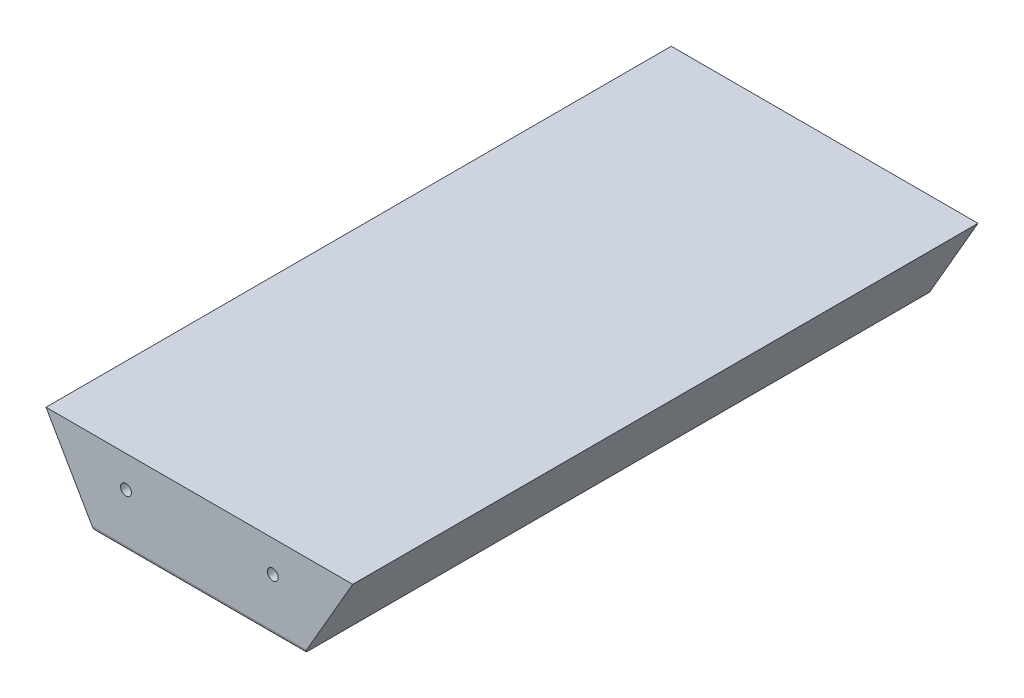
from build123d import *

# Parameters (mm, degrees)
BOSS_EXTRUDE1_DEPTH = 100
SKETCH3_R           = 5
CUT_EXTRUDE2_DEPTH  = 15
BOSS_EXTRUDE5_DEPTH = 50
BOSS_EXTRUDE6_DEPTH = 48
FILLET1_R           = 1.8
SKETCH11_R          = 2.6
CUT_EXTRUDE3_DEPTH  = 15
SKETCH12_R          = 2.6
CUT_EXTRUDE4_DEPTH  = 15


with BuildPart() as part:
    # Sketch1 → Boss-Extrude1 (new body, symmetric)
    with BuildSketch(Plane.XY):
        Polygon((50, 0), (-50, 0), (-73.094010768, 40), (73.094010768, 40), align=None)
    extrude(amount=BOSS_EXTRUDE1_DEPTH, both=True)

    # Sketch3 → Cut-Extrude2 (cut)
    with BuildSketch(Plane.XZ):
        with Locations((0, 70)):
            Circle(SKETCH3_R)
        with Locations((0, -70)):
            Circle(SKETCH3_R)
        Circle(SKETCH3_R)
    extrude(amount=-CUT_EXTRUDE2_DEPTH, mode=Mode.SUBTRACT)

    # Sketch9 → Boss-Extrude5 (add)
    with BuildSketch(Plane(origin=(0, 0, -100), x_dir=(-1, 0, 0), z_dir=(0, 0, -1))):
        Polygon((50, 0), (-50, 0), (-73.094010768, 40), (73.094010768, 40), align=None)
    extrude(amount=BOSS_EXTRUDE5_DEPTH)

    # Sketch10 → Boss-Extrude6 (add)
    with BuildSketch(Plane.XY.offset(100)):
        Polygon((-50, 0), (50, 0), (73.094010768, 40), (-73.094010768, 40), align=None)
    extrude(amount=BOSS_EXTRUDE6_DEPTH)

    # Fillet1
    fillet1_edges = [part.edges().sort_by_distance(p)[0] for p in [
        (0, 0, 148),
    ]]
    fillet(fillet1_edges, radius=FILLET1_R)

    # Sketch11 → Cut-Extrude3 (cut)
    with BuildSketch(Plane.XY.offset(148)):
        with Locations((-35, 25)):
            Circle(SKETCH11_R)
        with Locations((35, 25)):
            Circle(SKETCH11_R)
    extrude(amount=-CUT_EXTRUDE3_DEPTH, mode=Mode.SUBTRACT)

    # Sketch12 → Cut-Extrude4 (cut)
    with BuildSketch(Plane(origin=(0, 0, -150), x_dir=(-1, 0, 0), z_dir=(0, 0, -1))):
        with Locations((-35, 25)):
            Circle(SKETCH12_R)
        with Locations((35, 25)):
            Circle(SKETCH12_R)
    extrude(amount=-CUT_EXTRUDE4_DEPTH, mode=Mode.SUBTRACT)


solid = part.part
